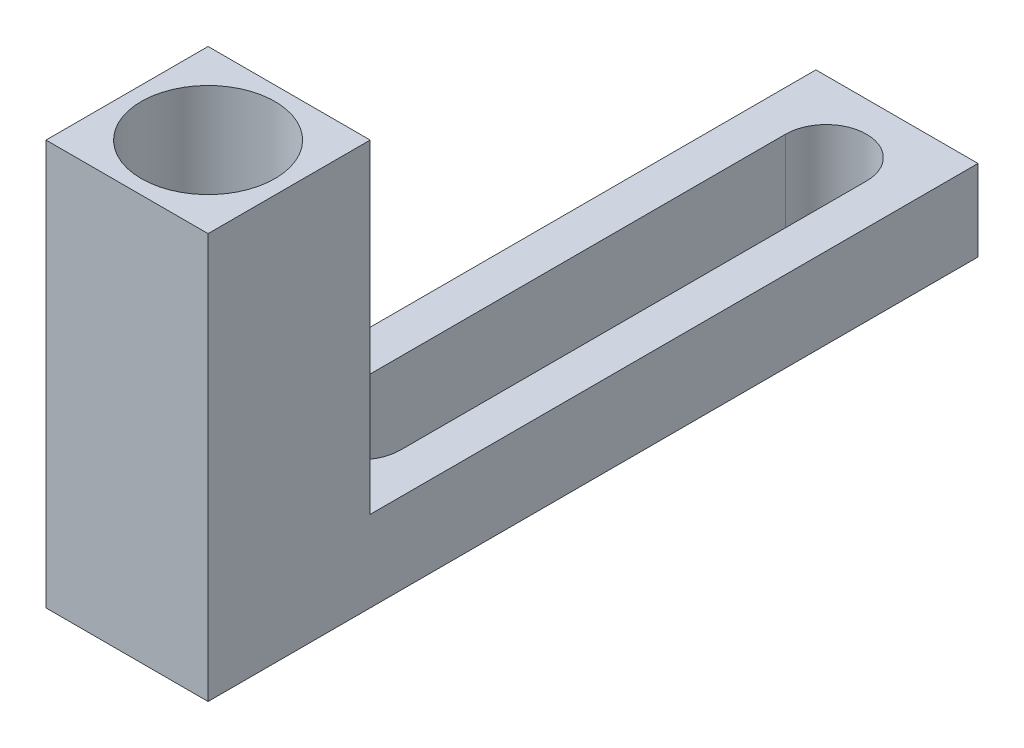
from build123d import *

# Parameters (mm, degrees)
SKETCH2_W           = 8
SKETCH2_H           = 30
BOSS_EXTRUDE1_DEPTH = 4
CUT_EXTRUDE1_DEPTH  = 5
SKETCH4_W           = 8
SKETCH4_H           = 8
BOSS_EXTRUDE2_DEPTH = 20
SKETCH5_R           = 3.3
CUT_EXTRUDE2_DEPTH  = 15.5
CUT_EXTRUDE3_REACH  = 10


with BuildPart() as part:
    # Sketch2 → Boss-Extrude1 (new body)
    with BuildSketch(Plane(origin=(0, 0, 0), x_dir=(1, 0, 0), z_dir=(0, 1, 0))):
        Rectangle(SKETCH2_W, SKETCH2_H)
    extrude(amount=BOSS_EXTRUDE1_DEPTH)

    # Sketch3 → Cut-Extrude1 (cut, through all)
    with BuildSketch(Plane(origin=(0, 0, 0), x_dir=(1, 0, 0), z_dir=(0, 1, 0))):
        with BuildLine():
            Line((-2, -11.5), (-2, 11.5))
            ThreePointArc((-2, 11.5), (0, 13.5), (2, 11.5))
            Line((2, 11.5), (2, -11.5))
            ThreePointArc((2, -11.5), (0, -13.5), (-2, -11.5))
        make_face()
    extrude(amount=CUT_EXTRUDE1_DEPTH, mode=Mode.SUBTRACT)

    # Sketch4 → Boss-Extrude2 (add)
    with BuildSketch(Plane(origin=(0, 0, 0), x_dir=(1, 0, 0), z_dir=(0, 1, 0))):
        with Locations((0, -19)):
            Rectangle(SKETCH4_W, SKETCH4_H)
    extrude(amount=BOSS_EXTRUDE2_DEPTH)

    # Sketch5 → Cut-Extrude2 (cut)
    with BuildSketch(Plane(origin=(0, 20, 0), x_dir=(1, 0, 0), z_dir=(0, 1, 0))):
        with Locations((0, -19)):
            Circle(SKETCH5_R)
    extrude(amount=-CUT_EXTRUDE2_DEPTH, mode=Mode.SUBTRACT)

    # Sketch6 → Cut-Extrude3 (cut, up to next)
    with BuildSketch(Plane.ZY.offset(4), mode=Mode.PRIVATE) as cut_extrude3_sk1:
        with BuildLine():
            Line((19.5, 4.5), (18.5, 4.5))
            ThreePointArc((18.5, 4.5), (17, 6), (18.5, 7.5))
            Line((18.5, 7.5), (19.5, 7.5))
            ThreePointArc((19.5, 7.5), (21, 6), (19.5, 4.5))
        make_face()
    cut_extrude3_tool1 = extrude(cut_extrude3_sk1.sketch, amount=-CUT_EXTRUDE3_REACH, mode=Mode.PRIVATE) & part.part
    add(cut_extrude3_tool1.solids().sort_by_distance((-4, 6, 19))[0], mode=Mode.SUBTRACT)


solid = part.part
